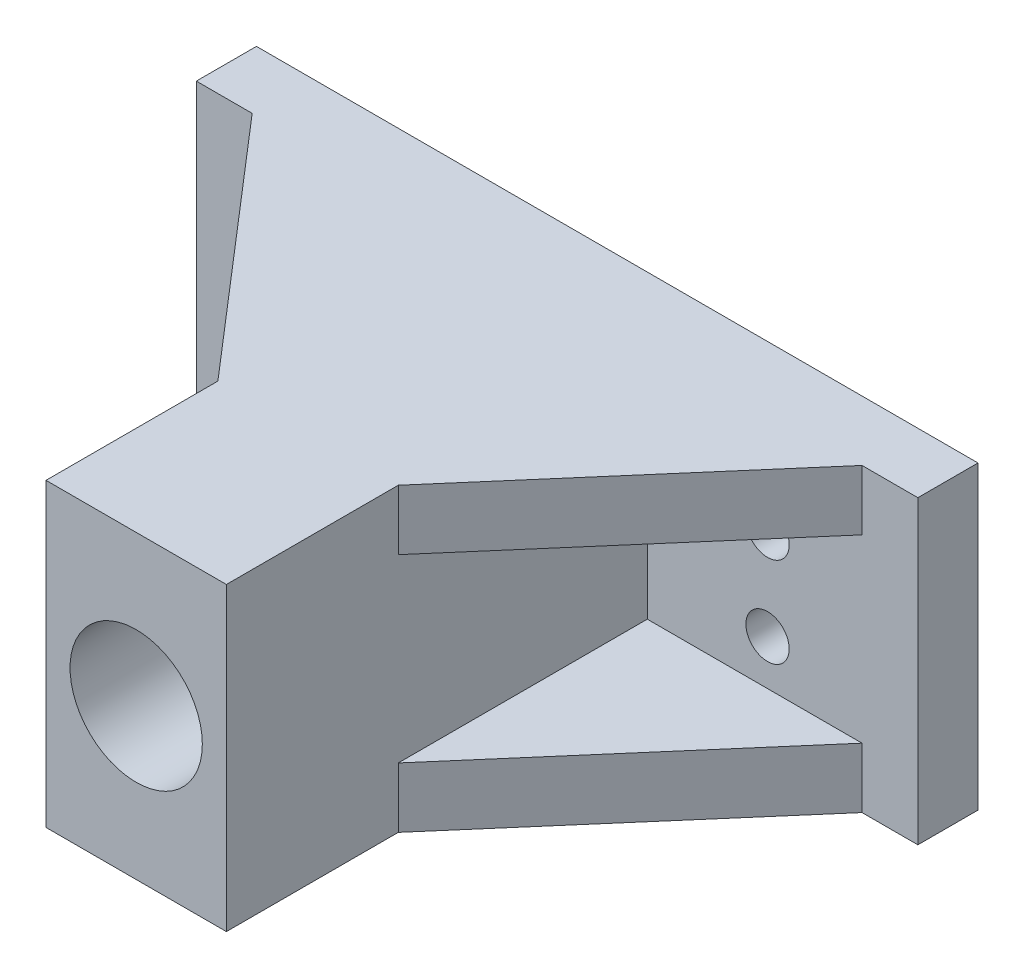
from build123d import *

# Parameters (mm, degrees)
SKETCH_1_W               = 40
SKETCH_1_H               = 15
EXTRUDE_1_DEPTH          = 5
SKETCH_2_R               = 5.5
SKETCH_2_R_2             = 1.8
CUT_EXTRUDE_1_DEPTH      = 5
SKETCH_3_W               = 15
SKETCH_3_H               = 15
SKETCH_3_R               = 5.05
EXTRUDE_2_DEPTH          = 25
SKETCH_4_R               = 5.5
CUT_EXTRUDE_2_DEPTH      = 31
SKETCH_5_W               = 10
SKETCH_5_H               = 15
EXTRUDE_3_DEPTH          = 5
SKETCH_6_R               = 1.8
CUT_EXTRUDE_3_DEPTH      = 5
SKETCH_7_W               = 60
SKETCH_7_H               = 5
EXTRUDE_4_DEPTH          = 5
SKETCH_8_W               = 15
SKETCH_8_H               = 5
EXTRUDE_5_DEPTH          = 25
RIB_1_REACH              = 51.244
SKETCH_9_WALL_W          = 127.83111072
SKETCH_9_WALL_H          = 5
MIRROR_2_COPY_1_REACH    = 51.244
MIRROR_2_COPY_1_SKETCH_W = 127.83111072
MIRROR_2_COPY_1_SKETCH_H = 5
SKETCH_11_R              = 1.8
EXTRUDE_6_DEPTH          = 5
SKETCH_12_R              = 1.8
CUT_EXTRUDE_4_DEPTH      = 5
SKETCH_13_W              = 15
SKETCH_13_H              = 25
SKETCH_13_R              = 5.5
EXTRUDE_7_DEPTH          = 10


with BuildPart() as part:
    # 草图1 → 凸台-拉伸1 (new body)
    with BuildSketch(Plane.XY):
        Rectangle(SKETCH_1_W, SKETCH_1_H)
    extrude(amount=EXTRUDE_1_DEPTH)

    # 草图2 → 切除-拉伸1 (cut)
    with BuildSketch(Plane.XY.offset(5)):
        Circle(SKETCH_2_R)
        with Locations((-12, 0)):
            Circle(SKETCH_2_R_2)
        with Locations(Location((12, 0, 0), (0, 0, 180))):
            Circle(SKETCH_2_R_2)
    extrude(amount=-CUT_EXTRUDE_1_DEPTH, mode=Mode.SUBTRACT)

    # 草图3 → 凸台-拉伸2 (add)
    with BuildSketch(Plane.XY.offset(5)):
        Rectangle(SKETCH_3_W, SKETCH_3_H)
        Circle(SKETCH_3_R, mode=Mode.SUBTRACT)
    extrude(amount=EXTRUDE_2_DEPTH)

    # 草图4 → 切除-拉伸2 (cut)
    with BuildSketch(Plane(origin=(0, 0, 5), x_dir=(-1, 0, 0), z_dir=(0, 0, -1))):
        with Locations(Location((0, 0, 0), (0, 0, 180))):
            Circle(SKETCH_4_R)
    extrude(amount=-CUT_EXTRUDE_2_DEPTH, mode=Mode.SUBTRACT)

    # 草图5 → 凸台-拉伸3 (add)
    with BuildSketch(Plane.XY.offset(5)):
        with Locations((-25, 0)):
            Rectangle(SKETCH_5_W, SKETCH_5_H)
        with Locations((25, 0)):
            Rectangle(SKETCH_5_W, SKETCH_5_H)
    extrude(amount=-EXTRUDE_3_DEPTH)

    # 草图6 → 切除-拉伸3 (cut)
    with BuildSketch(Plane.XY.offset(5)):
        with Locations((-24, 0)):
            Circle(SKETCH_6_R)
        with Locations(Location((24, 0, 0), (0, 0, 180))):
            Circle(SKETCH_6_R)
    extrude(amount=-CUT_EXTRUDE_3_DEPTH, mode=Mode.SUBTRACT)

    # 草图7 → 凸台-拉伸4 (add)
    with BuildSketch(Plane.XY.offset(5)):
        with Locations((0, 10)):
            Rectangle(SKETCH_7_W, SKETCH_7_H)
        with Locations((0, -10)):
            Rectangle(SKETCH_7_W, SKETCH_7_H)
    extrude(amount=-EXTRUDE_4_DEPTH)

    # 草图8 → 凸台-拉伸5 (add)
    with BuildSketch(Plane.XY.offset(5)):
        with Locations((0, 10)):
            Rectangle(SKETCH_8_W, SKETCH_8_H)
        with Locations((0, -10)):
            Rectangle(SKETCH_8_W, SKETCH_8_H)
    extrude(amount=EXTRUDE_5_DEPTH)

    # 草图9 wall → 筋1 (add, up to next)
    with BuildSketch(Plane(origin=(-16.427615827, 12.5, 15.353801199), x_dir=(0.653020400469, 0, 0.75734031754), z_dir=(0.75734031754, 0, -0.653020400469)), mode=Mode.PRIVATE) as rib_1_sk1:
        with Locations((0, 2.5)):
            Rectangle(SKETCH_9_WALL_W, SKETCH_9_WALL_H)
    rib_1_tool1 = extrude(rib_1_sk1.sketch, amount=RIB_1_REACH, mode=Mode.PRIVATE) - part.part
    rib_1 = rib_1_tool1.solids().sort_by_distance((-16.427615827, 12.5, 15.353801199))[0]
    add(rib_1)

    # 镜向1: 筋1 across plane
    add(rib_1.mirror(Plane.ZX))

    # 镜向2: 筋1 across plane
    add(rib_1.mirror(Plane.ZY))

    # 镜向2 copy 1 sketch → 镜向2 copy 1 (add, up to next)
    with BuildSketch(Plane(origin=(16.427615827, -12.5, 15.353801199), x_dir=(-0.653020400469, 0, 0.75734031754), z_dir=(-0.75734031754, 0, -0.653020400469)), mode=Mode.PRIVATE) as mirror_2_copy_1_sk1:
        with Locations((0, 2.5)):
            Rectangle(MIRROR_2_COPY_1_SKETCH_W, MIRROR_2_COPY_1_SKETCH_H)
    mirror_2_copy_1_tool1 = extrude(mirror_2_copy_1_sk1.sketch, amount=MIRROR_2_COPY_1_REACH, mode=Mode.PRIVATE) - part.part
    add(mirror_2_copy_1_tool1.solids().sort_by_distance((16.427615827, -12.5, 15.353801199))[0])

    # 草图11 → 凸台-拉伸6 (add)
    with BuildSketch(Plane.XY.offset(5)):
        with Locations((-24, 0)):
            Circle(SKETCH_11_R)
        with Locations((-12, 0)):
            Circle(SKETCH_11_R)
        with Locations((12, 0)):
            Circle(SKETCH_11_R)
        with Locations((24, 0)):
            Circle(SKETCH_11_R)
    extrude(amount=-EXTRUDE_6_DEPTH)

    # 草图12 → 切除-拉伸4 (cut)
    with BuildSketch(Plane.XY.offset(5)):
        with Locations((-17.5, 3.75)):
            Circle(SKETCH_12_R)
        with Locations(Location((-17.5, -3.75, 0), (0, 0, 180))):
            Circle(SKETCH_12_R)
        with Locations((17.5, -3.75)):
            Circle(SKETCH_12_R)
        with Locations(Location((17.5, 3.75, 0), (0, 0, 180))):
            Circle(SKETCH_12_R)
    extrude(amount=-CUT_EXTRUDE_4_DEPTH, mode=Mode.SUBTRACT)

    # 草图13 → 凸台-拉伸7 (add)
    with BuildSketch(Plane.XY.offset(30)):
        Rectangle(SKETCH_13_W, SKETCH_13_H)
        Circle(SKETCH_13_R, mode=Mode.SUBTRACT)
    extrude(amount=EXTRUDE_7_DEPTH)


solid = part.part
